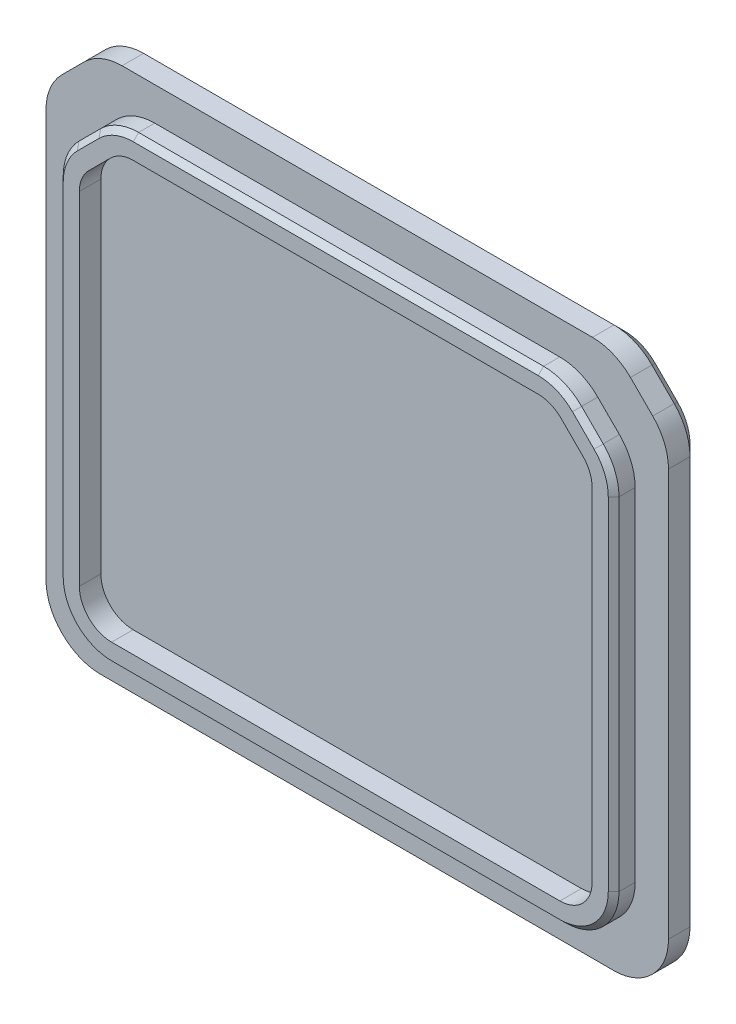
from build123d import *

# Parameters (mm, degrees)
BOSS_EXTRUDE1_DEPTH = 3
BOSS_EXTRUDE2_DEPTH = 2
CHAMFER1_SIZE       = 1
FILLET1_R           = 3
FILLET2_R           = 5
CHAMFER2_SIZE       = 0.5


with BuildPart() as part:
    # Sketch2 → Boss-Extrude1 (new body)
    with BuildSketch(Plane(origin=(0, 0, -23.390463949), x_dir=(-1, 0, 0), z_dir=(0, 0, -1))):
        with BuildLine():
            Line((21.428932188, 26), (-22.307932188, 26))
            ThreePointArc((-22.307932188, 26), (-24.22134935, 25.619397663), (-25.843466094, 24.535533906))
            Line((-25.843466094, 24.535533906), (-27.914533906, 22.464466094))
            ThreePointArc((-27.914533906, 22.464466094), (-28.998397663, 20.84234935), (-29.379, 18.928932188))
            Line((-29.379, 18.928932188), (-29.379, -18.928932188))
            ThreePointArc((-29.379, -18.928932188), (-28.998397663, -20.84234935), (-27.914533906, -22.464466094))
            Line((-27.914533906, -22.464466094), (-27.843466094, -22.535533906))
            ThreePointArc((-27.843466094, -22.535533906), (-26.22134935, -23.619397663), (-24.307932188, -24))
            Line((-24.307932188, -24), (23.428932188, -24))
            ThreePointArc((23.428932188, -24), (25.34234935, -23.619397663), (26.964466094, -22.535533906))
            Line((26.964466094, -22.535533906), (27.035533906, -22.464466094))
            ThreePointArc((27.035533906, -22.464466094), (28.119397663, -20.84234935), (28.5, -18.928932188))
            Line((28.5, -18.928932188), (28.5, 18.928932188))
            ThreePointArc((28.5, 18.928932188), (28.119397663, 20.84234935), (27.035533906, 22.464466094))
            Line((27.035533906, 22.464466094), (24.964466094, 24.535533906))
            ThreePointArc((24.964466094, 24.535533906), (23.34234935, 25.619397663), (21.428932188, 26))
        make_face()
    extrude(amount=BOSS_EXTRUDE1_DEPTH)

    # Sketch3 → Boss-Extrude2 (add)
    with BuildSketch(Plane(origin=(0, 0, -23.390463949), x_dir=(-1, 0, 0), z_dir=(0, 0, -1))):
        Polygon((-26.279, -20.9), (25.4, -20.9), (25.4, 17.958578644), (20.458578644, 22.9), (-21.337578644, 22.9), (-26.279, 17.958578644), align=None)
        Polygon((-24.279, -18.9), (23.4, -18.9), (23.4, 17.130151519), (19.630151519, 20.9), (-20.509151519, 20.9), (-24.279, 17.130151519), align=None, mode=Mode.SUBTRACT)
    extrude(amount=-BOSS_EXTRUDE2_DEPTH)

    # Chamfer1
    chamfer1_edges = [part.edges().sort_by_distance(p)[0] for p in [
        (28.998397663, 20.84234935, -26.390463949),
        (29.379, 0, -26.390463949),
        (28.998397663, -20.84234935, -26.390463949),
        (27.879, -22.5, -26.390463949),
        (26.22134935, -23.619397663, -26.390463949),
        (0.4395, -24, -26.390463949),
        (-25.34234935, -23.619397663, -26.390463949),
        (-27, -22.5, -26.390463949),
        (-28.119397663, -20.84234935, -26.390463949),
        (-28.5, 0, -26.390463949),
        (24.22134935, 25.619397663, -26.390463949),
        (-28.119397663, 20.84234935, -26.390463949),
        (-26, 23.5, -26.390463949),
        (-23.34234935, 25.619397663, -26.390463949),
        (0.4395, 26, -26.390463949),
        (26.879, 23.5, -26.390463949),
    ]]
    chamfer(chamfer1_edges, length=CHAMFER1_SIZE)

    # Fillet1
    fillet1_edges = [part.edges().sort_by_distance(p)[0] for p in [
        (24.279, 17.130151519, -22.390463949),
        (20.509151519, 20.9, -22.390463949),
        (-19.630151519, 20.9, -22.390463949),
        (-23.4, 17.130151519, -22.390463949),
        (-23.4, -18.9, -22.390463949),
        (24.279, -18.9, -22.390463949),
    ]]
    fillet(fillet1_edges, radius=FILLET1_R)

    # Fillet2
    fillet2_edges = [part.edges().sort_by_distance(p)[0] for p in [
        (26.279, -20.9, -22.390463949),
        (26.279, 17.958578644, -22.390463949),
        (21.337578644, 22.9, -22.390463949),
        (-20.458578644, 22.9, -22.390463949),
        (-25.4, 17.958578644, -22.390463949),
        (-25.4, -20.9, -22.390463949),
    ]]
    fillet(fillet2_edges, radius=FILLET2_R)

    # Chamfer2
    chamfer2_edges = [part.edges().sort_by_distance(p)[0] for p in [
        (-25.4, -0.006244584, -21.390463949),
        (-22.929289322, 20.429289322, -21.390463949),
        (26.279, -0.006244584, -21.390463949),
        (23.808289322, 20.429289322, -21.390463949),
        (0.4395, 22.9, -21.390463949),
        (0.4395, -20.9, -21.390463949),
        (24.814533906, -19.435533906, -21.390463949),
        (-23.935533906, -19.435533906, -21.390463949),
        (25.898397663, 17.800927994, -21.390463949),
        (21.179927994, 22.519397663, -21.390463949),
        (-20.300927994, 22.519397663, -21.390463949),
        (-25.019397663, 17.800927994, -21.390463949),
    ]]
    chamfer(chamfer2_edges, length=CHAMFER2_SIZE)


solid = part.part
